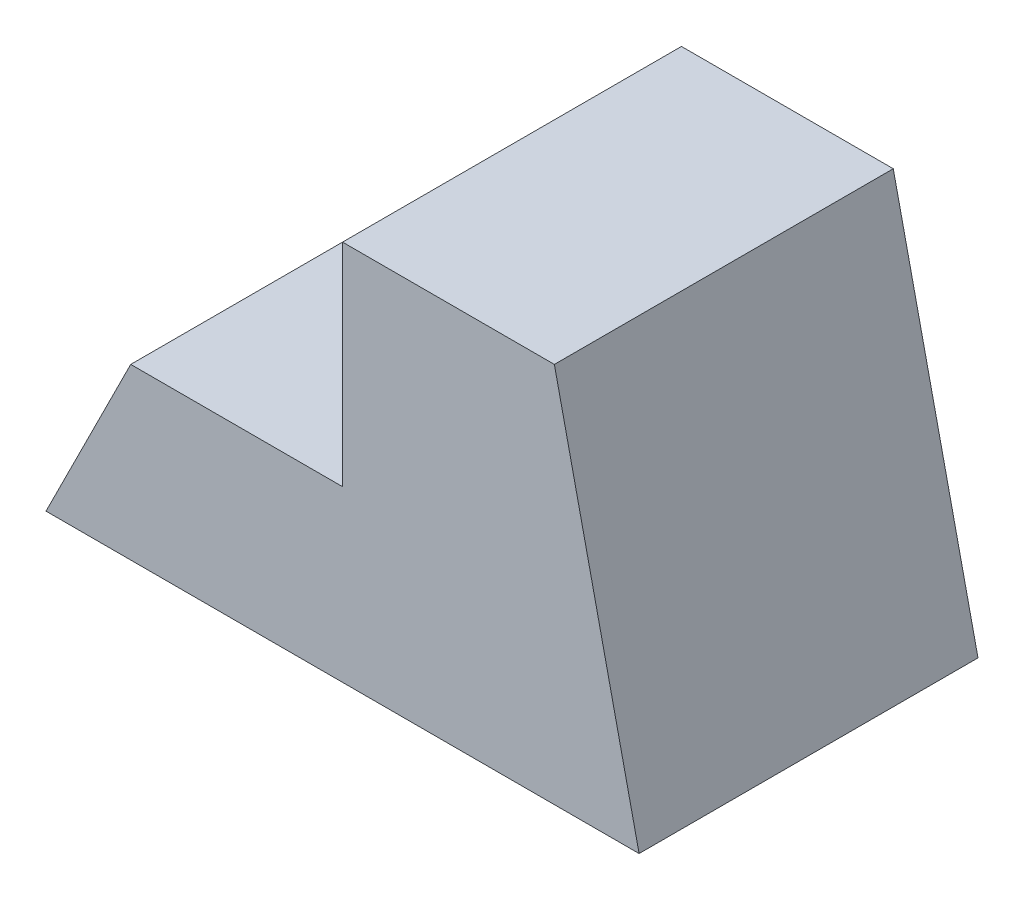
from build123d import *

# Parameters (mm, degrees)
BOSS_EXTRUDE1_DEPTH = 40


with BuildPart() as part:
    # Sketch2 → Boss-Extrude1 (new body)
    with BuildSketch(Plane.XY):
        Polygon((0, 0), (70, 0), (60, 45), (35, 45), (35, 20), (10, 20), align=None)
    extrude(amount=BOSS_EXTRUDE1_DEPTH)


solid = part.part
